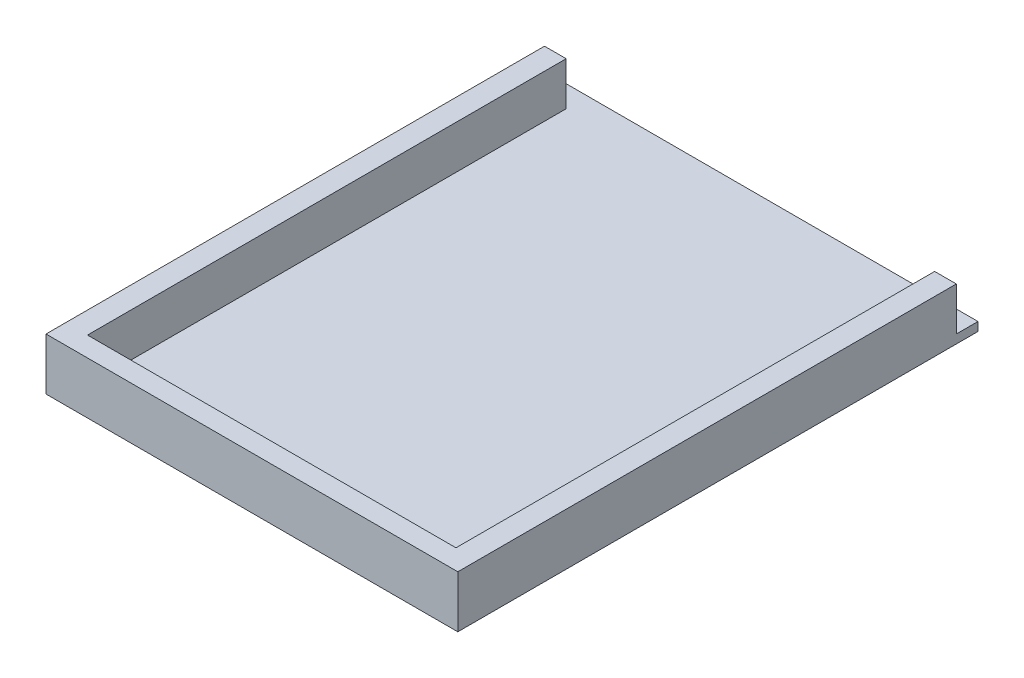
from build123d import *

# Parameters (mm, degrees)
SKETCH1_W           = 241.3
SKETCH1_H           = 304.8
SKETCH1_W_2         = 215.9
SKETCH1_H_2         = 279.4
BOSS_EXTRUDE1_DEPTH = 5.08
BOSS_EXTRUDE2_DEPTH = 25.4


with BuildPart() as part:
    # Sketch1 → Boss-Extrude1 (new body)
    with BuildSketch(Plane(origin=(0, 0, 0), x_dir=(1, 0, 0), z_dir=(0, 1, 0))):
        Rectangle(SKETCH1_W, SKETCH1_H)
        Rectangle(SKETCH1_W_2, SKETCH1_H_2, mode=Mode.SUBTRACT)
        Rectangle(SKETCH1_W_2, SKETCH1_H_2)
    extrude(amount=BOSS_EXTRUDE1_DEPTH)

    # Sketch2 → Boss-Extrude2 (add)
    with BuildSketch(Plane(origin=(0, 5.08, 0), x_dir=(1, 0, 0), z_dir=(0, 1, 0))):
        Polygon((-107.95, 139.7), (-120.65, 139.7), (-120.65, -152.4), (120.65, -152.4), (120.65, 139.7), (107.95, 139.7), (107.95, -140.783695347), (-107.95, -140.783695347), align=None)
    extrude(amount=BOSS_EXTRUDE2_DEPTH)


solid = part.part
